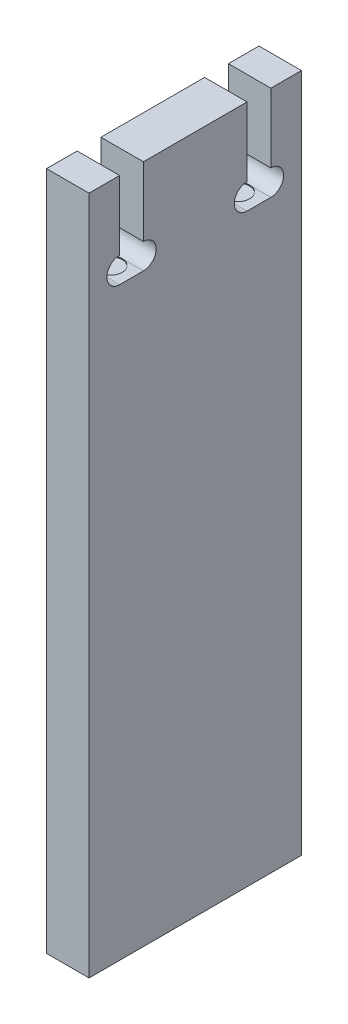
from build123d import *

# Parameters (mm, degrees)
EXTRUDE_1_DEPTH     = 2.5
SKETCH_2_R          = 1.4
CUT_EXTRUDE_1_DEPTH = 0.1


with BuildPart() as part:
    # 草图1 → 凸台-拉伸1 (new body, symmetric)
    with BuildSketch(Plane(origin=(0, 0, 0), x_dir=(0, 0, -1), z_dir=(1, 0, 0))):
        with BuildLine():
            Line((6.4, 80), (18.6, 80))
            Line((18.6, 80), (18.6, 71.8744))
            ThreePointArc((18.6, 71.8744), (17.1, 70.3744), (18.6, 68.8744))
            Line((18.6, 68.8744), (21.4, 68.8744))
            ThreePointArc((21.4, 68.8744), (22.9, 70.3744), (21.4, 71.8744))
            Line((21.4, 71.8744), (21.4, 80))
            Line((21.4, 80), (25, 80))
            Line((25, 80), (25, 0))
            Line((25, 0), (0, 0))
            Line((0, 0), (0, 80))
            Line((0, 80), (3.6, 80))
            Line((3.6, 80), (3.6, 71.8744))
            ThreePointArc((3.6, 71.8744), (2.1, 70.3744), (3.6, 68.8744))
            Line((3.6, 68.8744), (6.4, 68.8744))
            ThreePointArc((6.4, 68.8744), (7.9, 70.3744), (6.4, 71.8744))
            Line((6.4, 71.8744), (6.4, 80))
        make_face()
    extrude(amount=EXTRUDE_1_DEPTH, both=True)

    # 草图2 → 切除-拉伸1 (cut)
    with BuildSketch(Plane(origin=(0, 68.8744, 0), x_dir=(1, 0, 0), z_dir=(0, 1, 0))):
        with Locations((0, 20)):
            Circle(SKETCH_2_R)
        with Locations((0, 5)):
            Circle(SKETCH_2_R)
    extrude(amount=-CUT_EXTRUDE_1_DEPTH, mode=Mode.SUBTRACT)


solid = part.part
